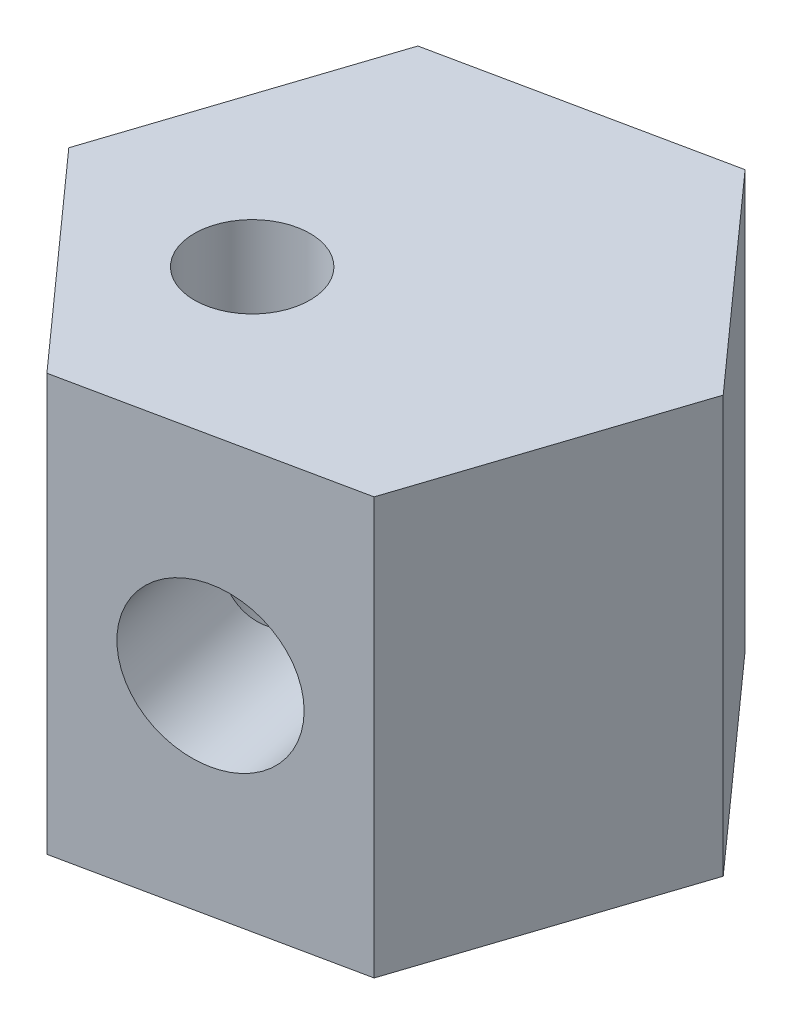
from build123d import *

# Parameters (mm, degrees)
BOSS_EXTRUDE1_DEPTH = 28.83
SKETCH2_R           = 5.475
CUT_EXTRUDE1_DEPTH  = 82
SKETCH3_R           = 4
CUT_EXTRUDE4_DEPTH  = 29.83


with BuildPart() as part:
    # Sketch1 → Boss-Extrude1 (new body)
    with BuildSketch(Plane(origin=(0, 0, 0), x_dir=(1, 0, 0), z_dir=(0, 1, 0))):
        Polygon((5.97883519, 18.175658977), (-12.75116481, 14.265652648), (-18.73, -3.910006329), (-5.97883519, -18.175658977), (12.75116481, -14.265652648), (18.73, 3.910006329), align=None)
    extrude(amount=BOSS_EXTRUDE1_DEPTH)

    # Sketch2 → Cut-Extrude1 (cut)
    with BuildSketch(Plane(origin=(3.38616481, 0, 16.220655813), x_dir=(0.97889766, 0, -0.204351097), z_dir=(0.204351097, 0, 0.97889766))):
        with Locations((0, 14.415)):
            Circle(SKETCH2_R)
    extrude(amount=-CUT_EXTRUDE1_DEPTH, mode=Mode.SUBTRACT)

    # Sketch3 → Cut-Extrude4 (cut, through all)
    with BuildSketch(Plane(origin=(0, 28.83, 0), x_dir=(1, 0, 0), z_dir=(0, 1, 0))):
        with Locations((-5.253979625, -4.69620015)):
            Circle(SKETCH3_R)
    extrude(amount=-CUT_EXTRUDE4_DEPTH, mode=Mode.SUBTRACT)


solid = part.part
